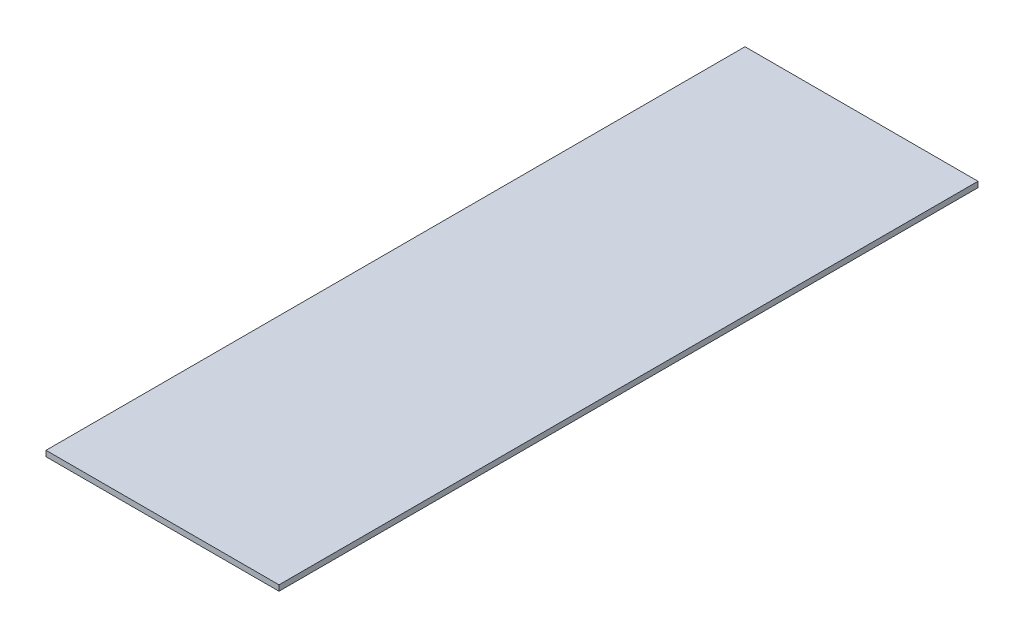
from build123d import *

# Parameters (mm, degrees)
SKETCH_1_W      = 5000
SKETCH_1_H      = 15000
EXTRUDE_1_DEPTH = 120


with BuildPart() as part:
    # 草图1 → 凸台-拉伸1 (new body)
    with BuildSketch(Plane(origin=(0, 0, 0), x_dir=(1, 0, 0), z_dir=(0, 1, 0))):
        Rectangle(SKETCH_1_W, SKETCH_1_H)
    extrude(amount=-EXTRUDE_1_DEPTH)


solid = part.part
